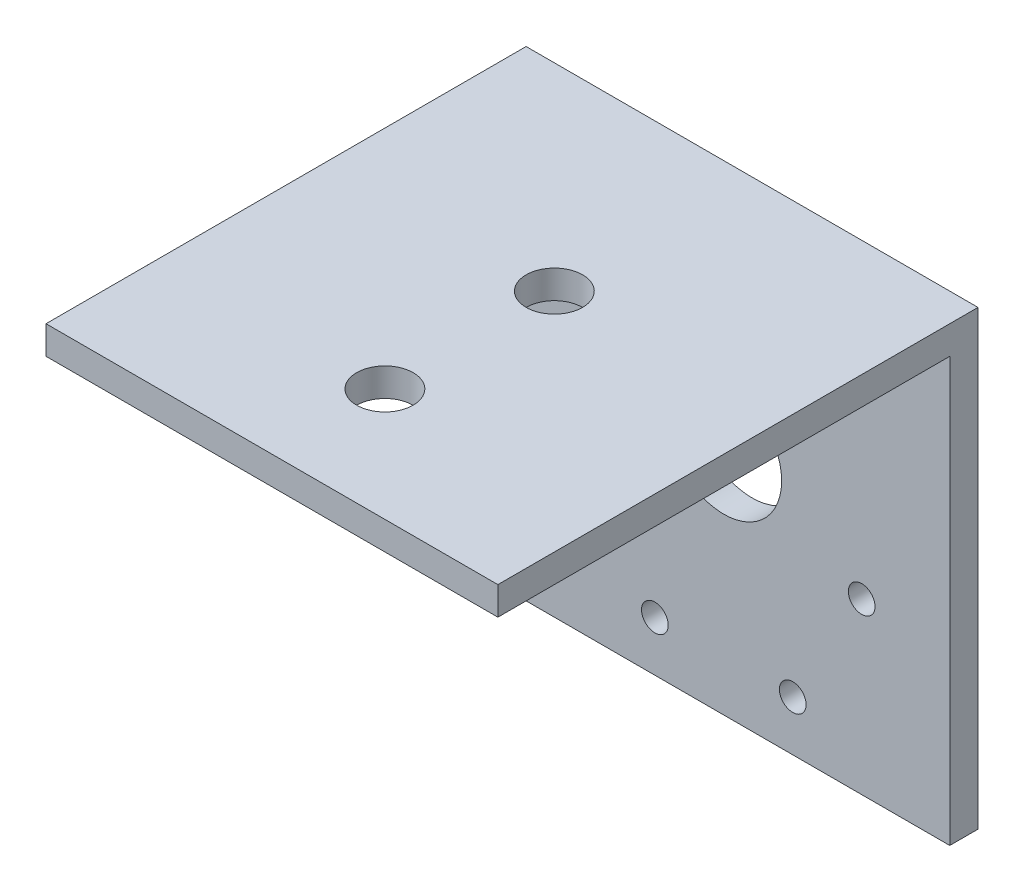
from build123d import *

# Parameters (mm, degrees)
SKETCH1_W           = 50.8
SKETCH1_H           = 50.8
SKETCH1_R           = 6.5
SKETCH1_R_2         = 1.5
BOSS_EXTRUDE1_DEPTH = 3.175
SKETCH2_W           = 50.8
SKETCH2_H           = 3.175
BOSS_EXTRUDE2_DEPTH = 50.8
SKETCH3_R           = 3.175
CUT_EXTRUDE1_DEPTH  = 4.175


with BuildPart() as part:
    # Sketch1 → Boss-Extrude1 (new body)
    with BuildSketch(Plane.XY):
        with Locations((25.4, 25.4)):
            Rectangle(SKETCH1_W, SKETCH1_H)
        with Locations((25.4, 26.05)):
            Circle(SKETCH1_R, mode=Mode.SUBTRACT)
        with Locations((9.9, 19.05)):
            Circle(SKETCH1_R_2, mode=Mode.SUBTRACT)
        with Locations((40.9, 19.05)):
            Circle(SKETCH1_R_2, mode=Mode.SUBTRACT)
        with Locations((33.15, 5.626606241)):
            Circle(SKETCH1_R_2, mode=Mode.SUBTRACT)
        with Locations((17.65, 5.626606241)):
            Circle(SKETCH1_R_2, mode=Mode.SUBTRACT)
        with Locations((17.65, 32.473393759)):
            Circle(SKETCH1_R_2, mode=Mode.SUBTRACT)
        with Locations((33.15, 32.473393759)):
            Circle(SKETCH1_R_2, mode=Mode.SUBTRACT)
    extrude(amount=BOSS_EXTRUDE1_DEPTH)

    # Sketch2 → Boss-Extrude2 (add)
    with BuildSketch(Plane.XY.offset(3.175)):
        with Locations((25.4, 49.2125)):
            Rectangle(SKETCH2_W, SKETCH2_H)
    extrude(amount=BOSS_EXTRUDE2_DEPTH)

    # Sketch3 → Cut-Extrude1 (cut, through all)
    with BuildSketch(Plane.XZ.offset(-47.625)):
        with Locations((25.4, 41.275)):
            Circle(SKETCH3_R)
        with Locations((25.4, 22.225)):
            Circle(SKETCH3_R)
    extrude(amount=-CUT_EXTRUDE1_DEPTH, mode=Mode.SUBTRACT)


solid = part.part
